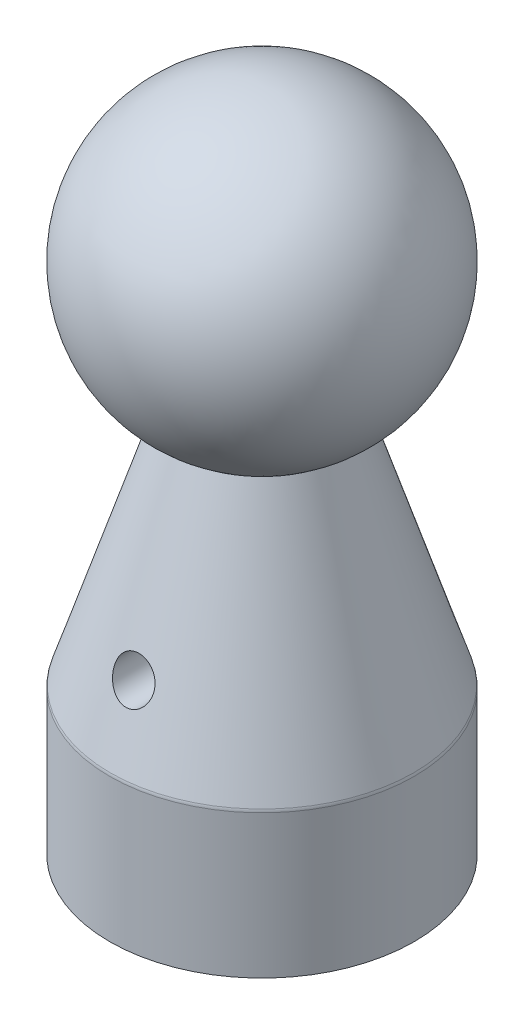
from build123d import *

# Parameters (mm, degrees)
SKETCH2_R               = 3.3655
CUT_EXTRUDE1_DEPTH      = 26.4
CUT_EXTRUDE1_DEPTH_BACK = 26.4
FILLET1_R               = 1.6002
CHAMFER1_SIZE           = 0.4699
CHAMFER2_SIZE           = 0.635


with BuildPart() as part:
    # Sketch1 → Revolve1 (revolve)
    with BuildSketch(Plane.XY, mode=Mode.PRIVATE) as revolve1_sk:
        with BuildLine():
            Line((25.4, 0), (25.4, 24.13))
            Line((25.4, 24.13), (12.7, 63.600954744))
            ThreePointArc((12.7, 63.600954744), (24.534515988, 92.172003746), (0, 110.998))
            Line((0, 110.998), (0, 28.575))
            Line((0, 28.575), (4.1656, 26.072055005))
            Line((4.1656, 26.072055005), (4.1656, 0.508))
            Line((4.1656, 0.508), (17.145, 0.508))
            Line((17.145, 0.508), (17.145, 0))
            Line((17.145, 0), (25.4, 0))
        make_face()
    revolve(revolve1_sk.sketch.rotate(Axis((0, 0, 0), (0, 1, 0)), 90), axis=Axis((0, 0, 0), (0, 1, 0)))  # turned: the seam where the file's is

    # Sketch2 → Cut-Extrude1 (cut, two sides)
    with BuildSketch(Plane.XY) as cut_extrude1_sk:
        with Locations(Location((0, 35.8775, 0), (0, 0, 90.000000009))):  # turned: the seam where the file's is
            Circle(SKETCH2_R)
    extrude(amount=CUT_EXTRUDE1_DEPTH, mode=Mode.SUBTRACT)
    extrude(cut_extrude1_sk.sketch, amount=-CUT_EXTRUDE1_DEPTH_BACK, mode=Mode.SUBTRACT)

    # Fillet1
    fillet1_edges = [part.edges().sort_by_distance(p)[0] for p in [
        (0, 24.13, 25.4),
    ]]
    fillet(fillet1_edges, radius=FILLET1_R)

    # Chamfer1
    chamfer1_edges = [part.edges().sort_by_distance(p)[0] for p in [
        (0, 0, 17.145),
    ]]
    chamfer(chamfer1_edges, length=CHAMFER1_SIZE)

    # Chamfer2
    chamfer2_edges = [part.edges().sort_by_distance(p)[0] for p in [
        (0, 0.508, 4.1656),
    ]]
    chamfer(chamfer2_edges, length=CHAMFER2_SIZE)


solid = part.part
